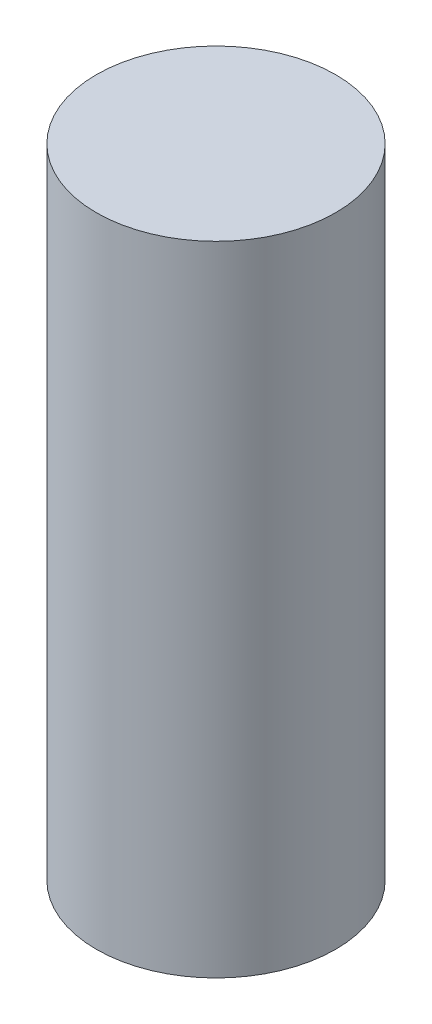
from build123d import *

# Parameters (mm, degrees)
SKETCH1_W = 15
SKETCH1_H = 80


with BuildPart() as part:
    # Sketch1 → Revolve1 (revolve)
    with BuildSketch(Plane.XY, mode=Mode.PRIVATE) as revolve1_sk:
        with Locations((7.5, 40)):
            Rectangle(SKETCH1_W, SKETCH1_H)
    revolve(revolve1_sk.sketch.rotate(Axis((0, 0, 0), (0, 1, 0)), 90), axis=Axis((0, 0, 0), (0, 1, 0)))  # turned: the seam where the file's is


solid = part.part
